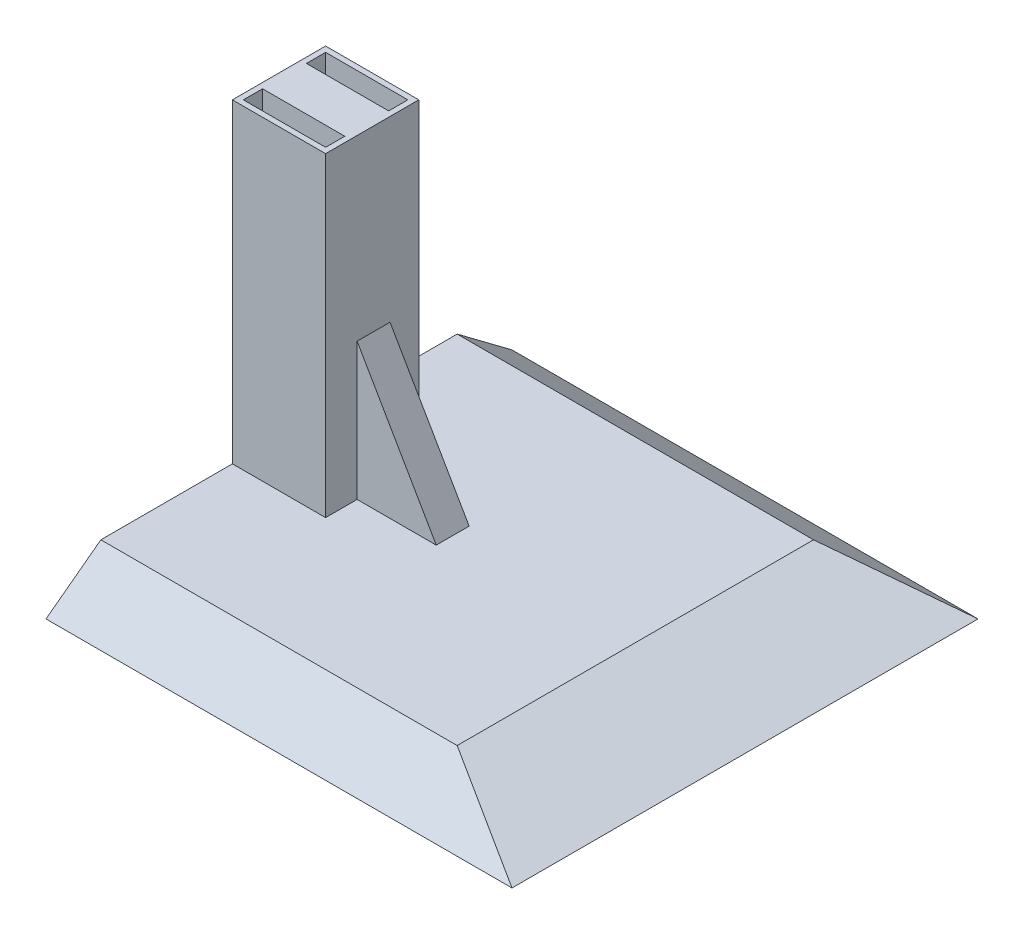
from build123d import *

# Parameters (mm, degrees)
SKETCH2_W           = 85
SKETCH2_H           = 85
SKETCH3_W           = 65
SKETCH3_H           = 65
SKETCH10_W          = 17
SKETCH10_H          = 17
BOSS_EXTRUDE5_DEPTH = 57.5
SKETCH11_W          = 15
SKETCH11_H          = 3.5
CUT_EXTRUDE1_DEPTH  = 25
BOSS_EXTRUDE6_START = -5.75
BOSS_EXTRUDE6_DEPTH = 6


with BuildPart() as part:
    # Sketch2 → Loft1 section 0
    with BuildSketch(Plane(origin=(0, 0, 0), x_dir=(1, 0, 0), z_dir=(0, 1, 0))):
        Rectangle(SKETCH2_W, SKETCH2_H)
    # Sketch3 → Loft1 section 1
    with BuildSketch(Plane(origin=(0, 7.5, 0), x_dir=(1, 0, 0), z_dir=(0, 1, 0))):
        with Locations((-10, 0)):
            Rectangle(SKETCH3_W, SKETCH3_H)
    loft()

    # Sketch10 → Boss-Extrude5 (add)
    with BuildSketch(Plane(origin=(0, 7.5, 0), x_dir=(1, 0, 0), z_dir=(0, 1, 0))):
        with Locations((-34, 0)):
            Rectangle(SKETCH10_W, SKETCH10_H)
    extrude(amount=BOSS_EXTRUDE5_DEPTH)

    # Sketch11 → Cut-Extrude1 (cut)
    with BuildSketch(Plane(origin=(0, 65, 0), x_dir=(1, 0, 0), z_dir=(0, 1, 0))):
        with Locations((-34, 5.75)):
            Rectangle(SKETCH11_W, SKETCH11_H)
        with Locations((-34, -5.75)):
            Rectangle(SKETCH11_W, SKETCH11_H)
    extrude(amount=-CUT_EXTRUDE1_DEPTH, mode=Mode.SUBTRACT)

    # Sketch14 → Boss-Extrude6 (add)
    with BuildSketch(Plane.XY.offset(8.5).offset(BOSS_EXTRUDE6_START)):
        Polygon((-25.5, 32.5), (-11.06624327, 7.5), (-25.5, 7.5), align=None)
    extrude(amount=-BOSS_EXTRUDE6_DEPTH)


solid = part.part
